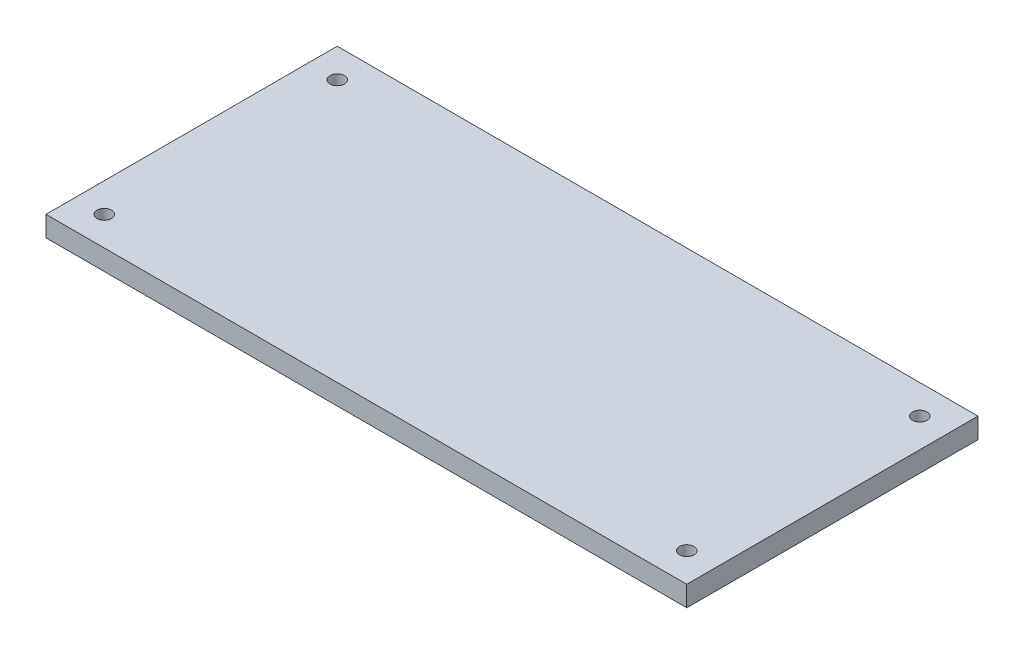
from build123d import *

# Parameters (mm, degrees)
SKETCH1_W           = 279.4
SKETCH1_H           = 127
SKETCH1_R           = 3.175
BOSS_EXTRUDE1_DEPTH = 8.89


with BuildPart() as part:
    # Sketch1 → Boss-Extrude1 (new body)
    with BuildSketch(Plane(origin=(0, 0, 0), x_dir=(1, 0, 0), z_dir=(0, 1, 0))):
        with Locations((139.7, -63.5)):
            Rectangle(SKETCH1_W, SKETCH1_H)
        with Locations((12.7, -12.7)):
            Circle(SKETCH1_R, mode=Mode.SUBTRACT)
        with Locations((12.7, -114.3)):
            Circle(SKETCH1_R, mode=Mode.SUBTRACT)
        with Locations((266.7, -12.7)):
            Circle(SKETCH1_R, mode=Mode.SUBTRACT)
        with Locations((266.7, -114.3)):
            Circle(SKETCH1_R, mode=Mode.SUBTRACT)
    extrude(amount=BOSS_EXTRUDE1_DEPTH)


solid = part.part
